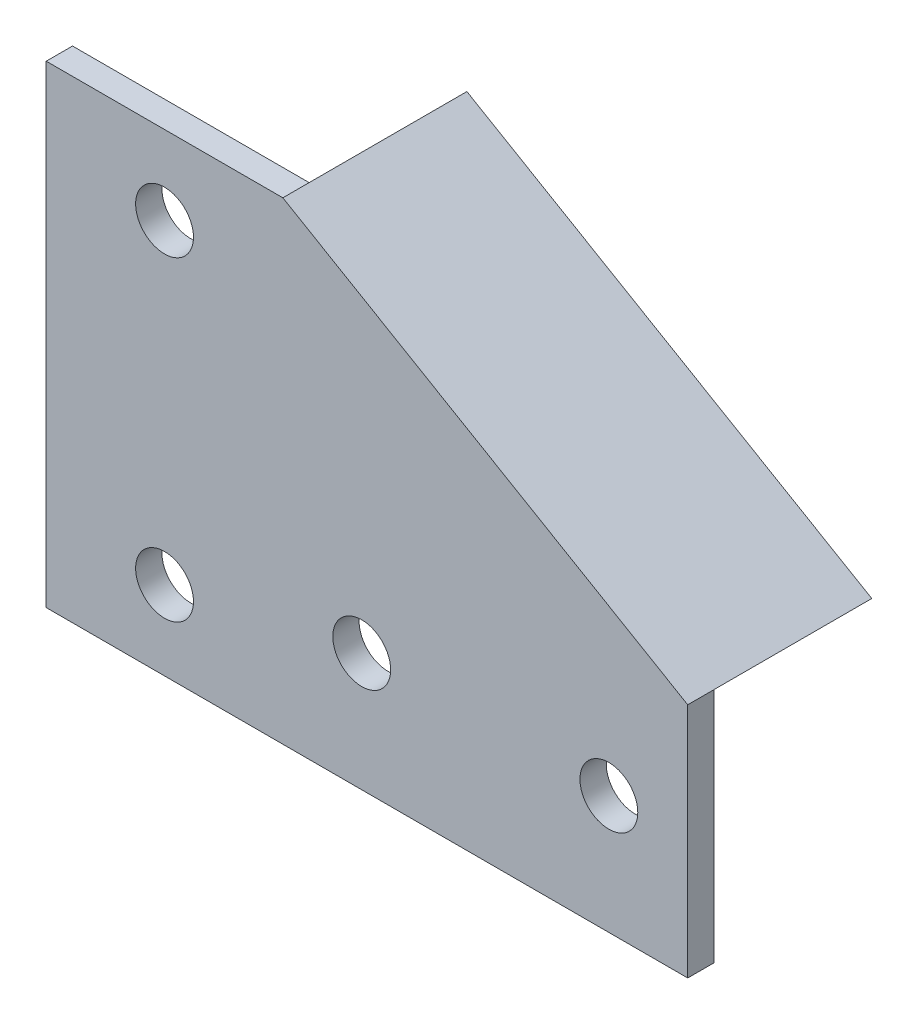
from build123d import *

# Parameters (mm, degrees)
ESQUISSE1_R        = 5.5
BOSS_EXTRU_1_DEPTH = 5
ESQUISSE2_W        = 10
ESQUISSE2_H        = 38
ESQUISSE2_W_2      = 25
ESQUISSE2_H_2      = 10
BOSS_EXTRU_2_DEPTH = 6
D_POUILLE3_ANGLE   = 10
BOSS_EXTRU_3_DEPTH = 30
CHANFREIN3_SIZE    = 5


with BuildPart() as part:
    # Esquisse1 → Boss.-Extru.1 (new body)
    with BuildSketch(Plane.XY):
        Polygon((0, 0), (0, 90), (45, 90), (122, 45), (122, 0), align=None)
        with Locations((22.5, 75)):
            Circle(ESQUISSE1_R, mode=Mode.SUBTRACT)
        with Locations((22.5, 15)):
            Circle(ESQUISSE1_R, mode=Mode.SUBTRACT)
        with Locations((107, 22.5)):
            Circle(ESQUISSE1_R, mode=Mode.SUBTRACT)
        with Locations((60, 22.5)):
            Circle(ESQUISSE1_R, mode=Mode.SUBTRACT)
    extrude(amount=BOSS_EXTRU_1_DEPTH)

    # Esquisse2 → Boss.-Extru.2 (add)
    with BuildSketch(Plane.XY):
        with Locations((22.5, 45)):
            Rectangle(ESQUISSE2_W, ESQUISSE2_H)
        with Locations((83.5, 22.5)):
            Rectangle(ESQUISSE2_W_2, ESQUISSE2_H_2)
    extrude(amount=-BOSS_EXTRU_2_DEPTH)

    # Dépouille3
    d_pouille3_faces = [part.faces().sort_by_distance(p)[0] for p in [
        (83.5, 27.5, -3),
        (96, 22.5, -3),
        (71, 22.5, -3),
        (83.5, 17.5, -3),
        (22.5, 26, -3),
        (27.5, 45, -3),
        (22.5, 64, -3),
        (17.5, 45, -3),
    ]]
    draft(d_pouille3_faces, Plane(origin=(0, 0, 0), x_dir=(-1, 0, 0), z_dir=(0, 0, -1)), D_POUILLE3_ANGLE)

    # Esquisse3 → Boss.-Extru.3 (add)
    with BuildSketch(Plane(origin=(0, 0, 0), x_dir=(-1, 0, 0), z_dir=(0, 0, -1))):
        Polygon((-122, 45), (-45, 45), (-45, 90), align=None)
    extrude(amount=BOSS_EXTRU_3_DEPTH)

    # Chanfrein3
    chanfrein3_edges = [part.edges().sort_by_distance(p)[0] for p in [
        (45, 45, -15),
    ]]
    chamfer(chanfrein3_edges, length=CHANFREIN3_SIZE)


solid = part.part
